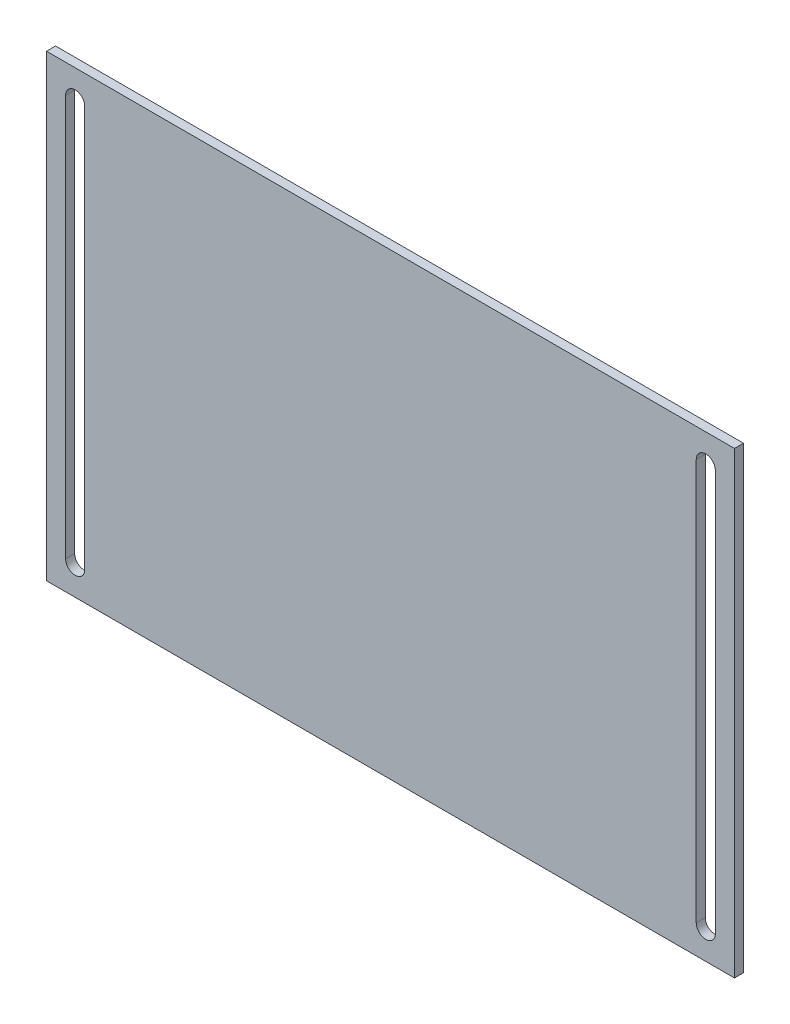
from build123d import *

# Parameters (mm, degrees)
SKETCH1_W           = 228.6
SKETCH1_H           = 152.4
BOSS_EXTRUDE1_DEPTH = 3


with BuildPart() as part:
    # Sketch1 → Boss-Extrude1 (new body)
    with BuildSketch(Plane.XY):
        Rectangle(SKETCH1_W, SKETCH1_H)
        with BuildLine():
            Line((-101.6, 66.675), (-101.6, -66.675))
            ThreePointArc((-101.6, -66.675), (-104.775, -69.85), (-107.95, -66.675))
            Line((-107.95, -66.675), (-107.95, 66.675))
            ThreePointArc((-107.95, 66.675), (-104.775, 69.85), (-101.6, 66.675))
        make_face(mode=Mode.SUBTRACT)
        with BuildLine():
            Line((107.95, 66.675), (107.95, -66.675))
            ThreePointArc((107.95, -66.675), (104.775, -69.85), (101.6, -66.675))
            Line((101.6, -66.675), (101.6, 66.675))
            ThreePointArc((101.6, 66.675), (104.775, 69.85), (107.95, 66.675))
        make_face(mode=Mode.SUBTRACT)
    extrude(amount=BOSS_EXTRUDE1_DEPTH)


solid = part.part
